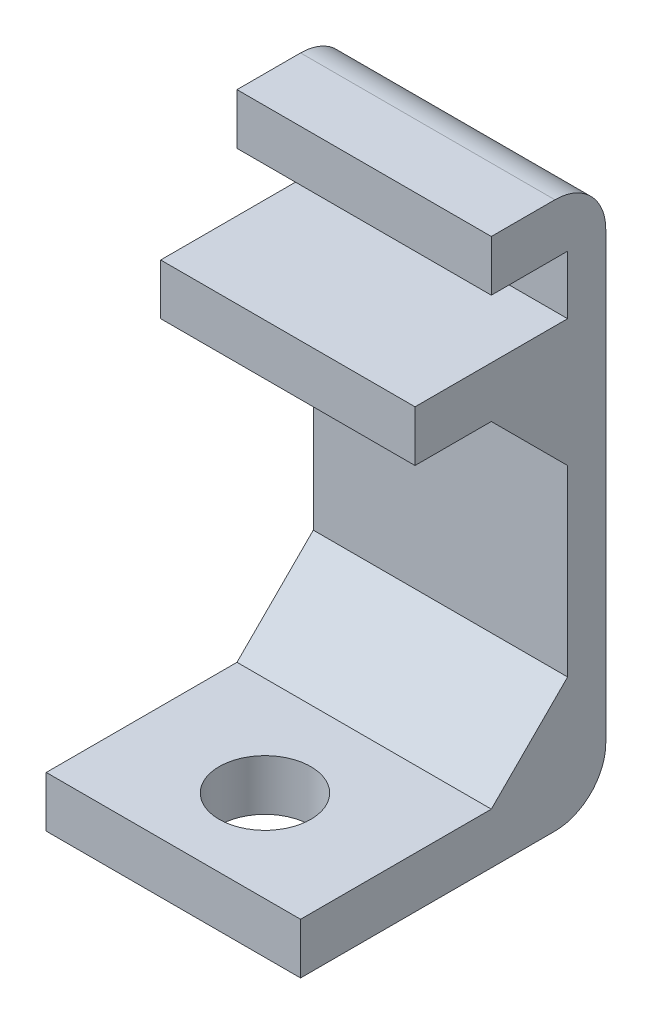
from build123d import *

# Parameters (mm, degrees)
BOSS_EXTRUDE1_DEPTH     = 5
CHAMFER1_SIZE           = 3
SKETCH2_R               = 1.8
CUT_EXTRUDE1_DEPTH      = 3
CUT_EXTRUDE1_DEPTH_BACK = 3
FILLET1_R               = 2


with BuildPart() as part:
    # Sketch1 → Boss-Extrude1 (new body, symmetric)
    with BuildSketch(Plane(origin=(0, 0, 0), x_dir=(0, 0, -1), z_dir=(1, 0, 0))):
        Polygon((-5.25, -8.75), (-5.25, -10.75), (6.75, -10.75), (6.75, 10.75), (2.25, 10.75), (2.25, 8.75), (5.25, 8.75), (5.25, 6.45), (-0.75, 6.45), (-0.75, 4.45), (5.25, 4.45), (5.25, -8.75), align=None)
    extrude(amount=BOSS_EXTRUDE1_DEPTH, both=True)

    # Chamfer1
    chamfer1_edges = [part.edges().sort_by_distance(p)[0] for p in [
        (0, -8.75, -5.25),
        (0, 4.45, -5.25),
    ]]
    chamfer(chamfer1_edges, length=CHAMFER1_SIZE)

    # Sketch2 → Cut-Extrude1 (cut, two sides)
    with BuildSketch(Plane(origin=(0, -8.75, 0), x_dir=(1, 0, 0), z_dir=(0, 1, 0))) as cut_extrude1_sk:
        with Locations((0, -1.65)):
            Circle(SKETCH2_R)
    extrude(amount=CUT_EXTRUDE1_DEPTH, mode=Mode.SUBTRACT)
    extrude(cut_extrude1_sk.sketch, amount=-CUT_EXTRUDE1_DEPTH_BACK, mode=Mode.SUBTRACT)

    # Fillet1
    fillet1_edges = [part.edges().sort_by_distance(p)[0] for p in [
        (0, 10.75, -6.75),
        (0, -10.75, -6.75),
    ]]
    fillet(fillet1_edges, radius=FILLET1_R)


solid = part.part
